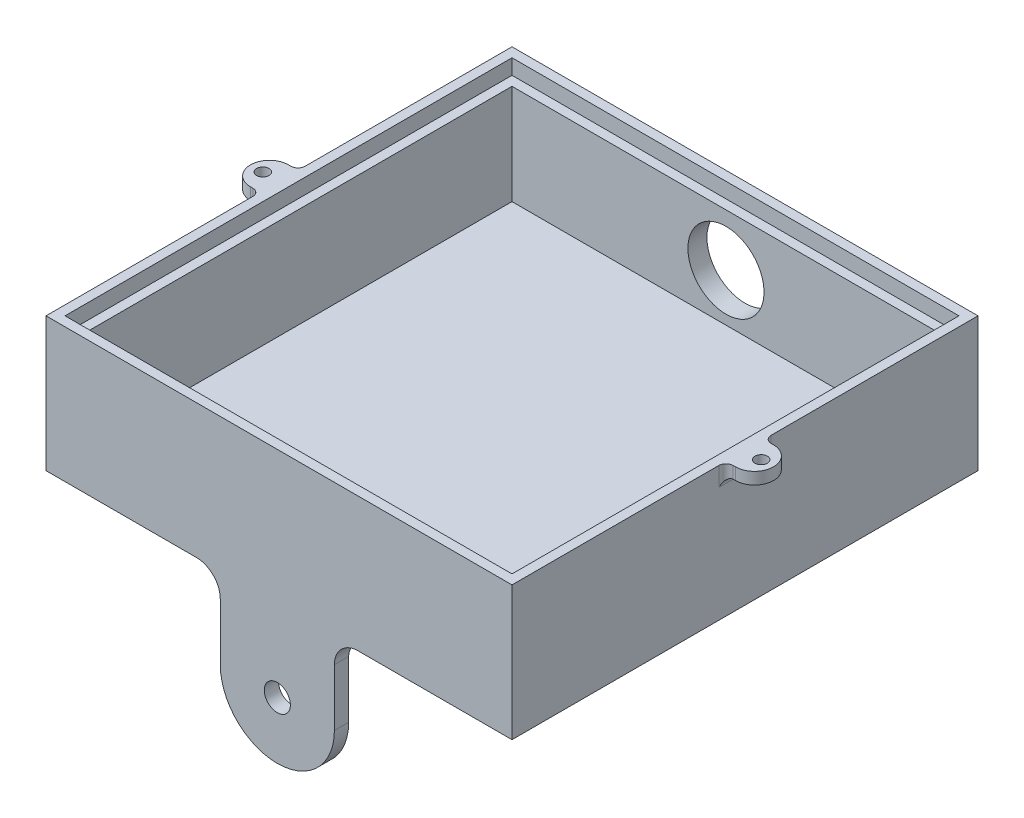
from build123d import *

# Parameters (mm, degrees)
SKETCH1_W           = 98
SKETCH1_H           = 98
BOSS_EXTRUDE1_DEPTH = 30
SKETCH2_W           = 94
SKETCH2_H           = 94
CUT_EXTRUDE1_DEPTH  = 5
SKETCH3_W           = 90
SKETCH3_H           = 90
CUT_EXTRUDE2_DEPTH  = 21
SKETCH4_W           = 98
SKETCH4_H           = 98
SKETCH4_W_2         = 94
SKETCH4_H_2         = 94
CUT_EXTRUDE3_DEPTH  = 1.8
SKETCH5_R           = 1.3
BOSS_EXTRUDE2_DEPTH = 2.5
FILLET1_R           = 1.5
FILLET2_R           = 1.5
CUT_EXTRUDE4_REACH  = 100
SKETCH6_R           = 8
SKETCH7_R           = 1.968352886
CUT_EXTRUDE5_DEPTH  = 1
SKETCH8_R           = 2.75
BOSS_EXTRUDE3_DEPTH = 3
FILLET3_R           = 5


with BuildPart() as part:
    # Sketch1 → Boss-Extrude1 (new body)
    with BuildSketch(Plane(origin=(0, 0, 0), x_dir=(1, 0, 0), z_dir=(0, 1, 0))):
        Rectangle(SKETCH1_W, SKETCH1_H)
    extrude(amount=BOSS_EXTRUDE1_DEPTH)

    # Sketch2 → Cut-Extrude1 (cut)
    with BuildSketch(Plane(origin=(0, 30, 0), x_dir=(1, 0, 0), z_dir=(0, 1, 0))):
        Rectangle(SKETCH2_W, SKETCH2_H)
    extrude(amount=-CUT_EXTRUDE1_DEPTH, mode=Mode.SUBTRACT)

    # Sketch3 → Cut-Extrude2 (cut)
    with BuildSketch(Plane(origin=(0, 25, 0), x_dir=(1, 0, 0), z_dir=(0, 1, 0))):
        Rectangle(SKETCH3_W, SKETCH3_H)
    extrude(amount=-CUT_EXTRUDE2_DEPTH, mode=Mode.SUBTRACT)

    # Sketch4 → Cut-Extrude3 (cut)
    with BuildSketch(Plane(origin=(0, 30, 0), x_dir=(1, 0, 0), z_dir=(0, 1, 0))):
        Rectangle(SKETCH4_W, SKETCH4_H)
        Rectangle(SKETCH4_W_2, SKETCH4_H_2, mode=Mode.SUBTRACT)
    extrude(amount=-CUT_EXTRUDE3_DEPTH, mode=Mode.SUBTRACT)

    # Sketch5 → Boss-Extrude2 (add)
    with BuildSketch(Plane(origin=(0, 28.2, 0), x_dir=(1, 0, 0), z_dir=(0, 1, 0))):
        with BuildLine():
            Line((-49, 4), (-51, 4))
            ThreePointArc((-51, 4), (-55, 0), (-51, -4))
            Line((-51, -4), (-49, -4))
            Line((-49, -4), (-49, 4))
        make_face()
        with Locations((-52.4, 0)):
            Circle(SKETCH5_R, mode=Mode.SUBTRACT)
        with BuildLine():
            Line((49, 4), (49, -4))
            Line((49, -4), (51, -4))
            ThreePointArc((51, -4), (55, 0), (51, 4))
            Line((51, 4), (49, 4))
        make_face()
        with Locations((52.4, 0)):
            Circle(SKETCH5_R, mode=Mode.SUBTRACT)
    extrude(amount=-BOSS_EXTRUDE2_DEPTH)

    # Fillet1
    fillet1_edges = [part.edges().sort_by_distance(p)[0] for p in [
        (-49, 25.7, 0),
        (-49, 26.95, -4),
        (-49, 26.95, 4),
    ]]
    fillet(fillet1_edges, radius=FILLET1_R)

    # Fillet2
    fillet2_edges = [part.edges().sort_by_distance(p)[0] for p in [
        (49, 26.95, -4),
        (49, 25.7, 0),
        (49, 26.95, 4),
    ]]
    fillet(fillet2_edges, radius=FILLET2_R)

    # Sketch6 → Cut-Extrude4 (cut, up to next)
    with BuildSketch(Plane(origin=(0, 0, -49), x_dir=(-1, 0, 0), z_dir=(0, 0, -1)), mode=Mode.PRIVATE) as cut_extrude4_sk1:
        with Locations((0, 14)):
            Circle(SKETCH6_R)
    cut_extrude4_tool1 = extrude(cut_extrude4_sk1.sketch, amount=-CUT_EXTRUDE4_REACH, mode=Mode.PRIVATE) & part.part
    add(cut_extrude4_tool1.solids().sort_by_distance((0, 14, -49))[0], mode=Mode.SUBTRACT)

    # Sketch7 → Cut-Extrude5 (cut)
    with BuildSketch(Plane.XZ):
        with BuildLine():
            Line((-4, -10), (-1, -10))
            Line((-1, -10), (1, -10))
            ThreePointArc((1, -10), (6, -5), (1, 0))
            ThreePointArc((1, 0), (6, 5), (1, 10))
            Line((1, 10), (-4, 10))
            Line((-4, 10), (-4, -10))
        make_face()
        with Locations((1, 5)):
            Circle(SKETCH7_R, mode=Mode.SUBTRACT)
        with Locations((1, -5)):
            Circle(SKETCH7_R, mode=Mode.SUBTRACT)
    extrude(amount=-CUT_EXTRUDE5_DEPTH, mode=Mode.SUBTRACT)

    # Sketch8 → Boss-Extrude3 (add)
    with BuildSketch(Plane.XY.offset(49)):
        with BuildLine():
            Line((11.648602748, -17), (11.648602748, 0))
            Line((11.648602748, 0), (-12.351397252, 0))
            Line((-12.351397252, 0), (-12.351397252, -17))
            ThreePointArc((-12.351397252, -17), (-0.351397252, -29), (11.648602748, -17))
        make_face()
        with Locations((-0.351397252, -17)):
            Circle(SKETCH8_R, mode=Mode.SUBTRACT)
    extrude(amount=-BOSS_EXTRUDE3_DEPTH)

    # Fillet3
    fillet3_edges = [part.edges().sort_by_distance(p)[0] for p in [
        (-0.351397252, 0, 46),
        (-12.351397252, 0, 47.5),
        (11.648602748, 0, 47.5),
    ]]
    fillet(fillet3_edges, radius=FILLET3_R)


solid = part.part
